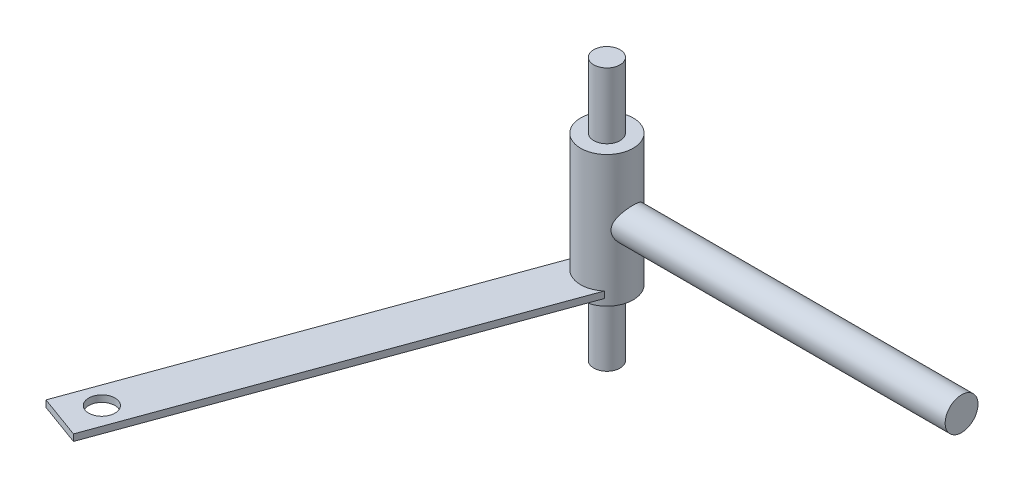
from build123d import *

# Parameters (mm, degrees)
SKETCH1_R           = 4
BOSS_EXTRUDE1_DEPTH = 40
SKETCH3_R           = 8
BOSS_EXTRUDE2_DEPTH = 20
SKETCH4_R           = 5
BOSS_EXTRUDE3_DEPTH = 108
SKETCH5_W           = 14
SKETCH5_H           = 2
BOSS_EXTRUDE4_DEPTH = 130
CUT_EXTRUDE1_REACH  = 176.108
SKETCH6_R           = 4


with BuildPart() as part:
    # Sketch1 → Boss-Extrude1 (new, symmetric)
    with BuildSketch(Plane(origin=(0, 0, 0), x_dir=(1, 0, 0), z_dir=(0, 1, 0))):
        Circle(SKETCH1_R)
    extrude(amount=BOSS_EXTRUDE1_DEPTH, both=True)

    # Sketch3 → Boss-Extrude2 (add, symmetric)
    with BuildSketch(Plane(origin=(0, 0, 0), x_dir=(1, 0, 0), z_dir=(0, 1, 0))):
        Circle(SKETCH3_R)
    extrude(amount=BOSS_EXTRUDE2_DEPTH, both=True)

    # Sketch4 → Boss-Extrude3 (add)
    with BuildSketch(Plane(origin=(0, 0, 0), x_dir=(0, 0, -1), z_dir=(1, 0, 0))):
        Circle(SKETCH4_R)
    extrude(amount=BOSS_EXTRUDE3_DEPTH)

    # Sketch5 → Boss-Extrude4 (add)
    with BuildSketch(Plane(origin=(0, 0, 0), x_dir=(0.939692620785908, 0, 0.34202014332566977), z_dir=(-0.34202014332566977, 0, 0.939692620785908))):
        with Locations((0, -17)):
            Rectangle(SKETCH5_W, SKETCH5_H)
    extrude(amount=BOSS_EXTRUDE4_DEPTH)

    # Sketch6 → Cut-Extrude1 (cut, up to next)
    with BuildSketch(Plane(origin=(0, -16, 0), x_dir=(1, 0, 0), z_dir=(0, 1, 0)), mode=Mode.PRIVATE) as cut_extrude1_sk1:
        with Locations((-41.042417199, -112.763114494)):
            Circle(SKETCH6_R)
    cut_extrude1_tool1 = extrude(cut_extrude1_sk1.sketch, amount=-CUT_EXTRUDE1_REACH, mode=Mode.PRIVATE) & part.part
    add(cut_extrude1_tool1.solids().sort_by_distance((-41.042417, -16, 112.763114))[0], mode=Mode.SUBTRACT)


solid = part.part
